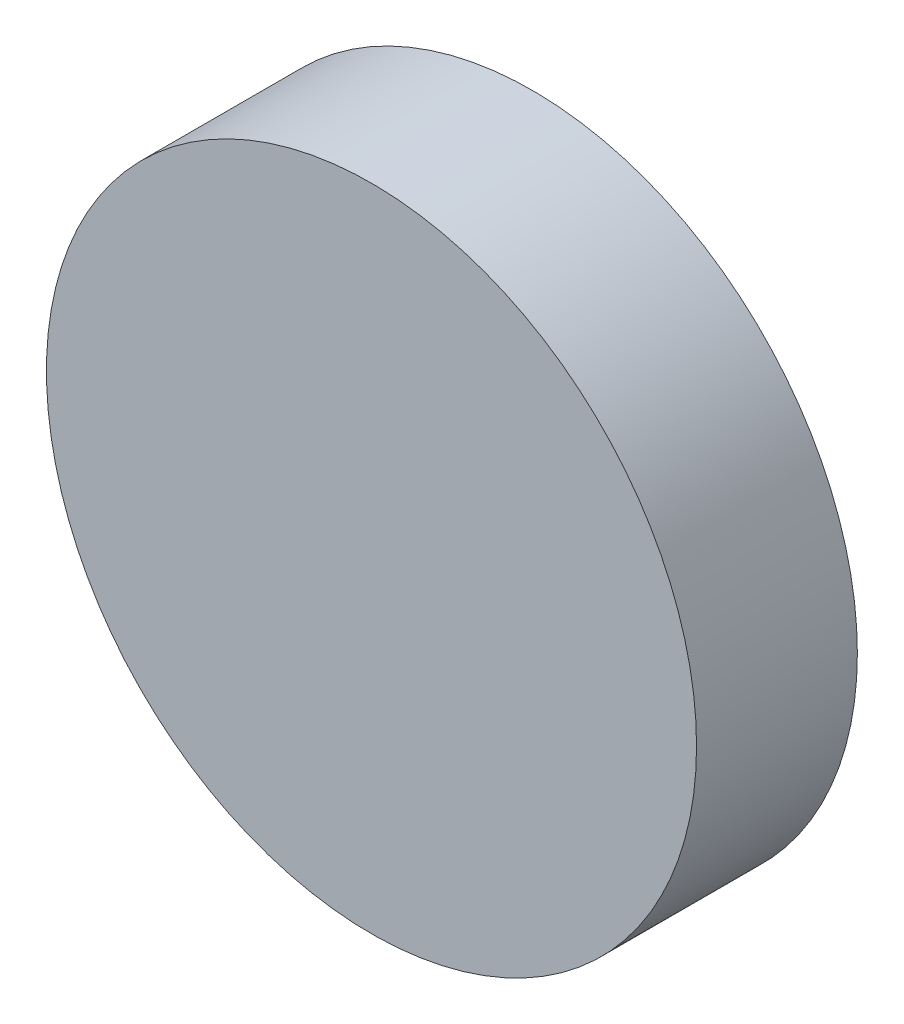
from build123d import *

# Parameters (mm, degrees)
SKETCH1_R           = 6.0071
BOSS_EXTRUDE1_DEPTH = 2.9718


with BuildPart() as part:
    # Sketch1 → Boss-Extrude1 (new body)
    with BuildSketch(Plane.XY):
        Circle(SKETCH1_R)
    extrude(amount=BOSS_EXTRUDE1_DEPTH)


solid = part.part
